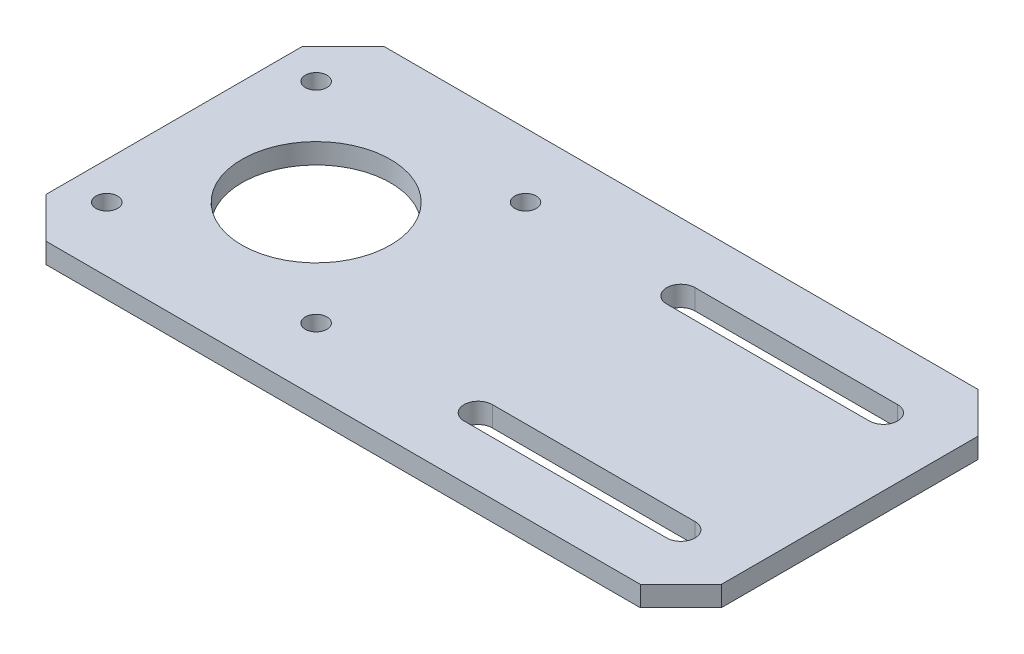
from build123d import *

# Parameters (mm, degrees)
SKETCH_1_W      = 100
SKETCH_1_H      = 50
SKETCH_1_R      = 11
SKETCH_1_R_2    = 1.6
EXTRUDE_1_DEPTH = 3
CHAMFER_1_SIZE  = 6


with BuildPart() as part:
    # 草图1 → 凸台-拉伸1 (new body)
    with BuildSketch(Plane(origin=(0, 0, 0), x_dir=(1, 0, 0), z_dir=(0, 1, 0))):
        with Locations((50, 25)):
            Rectangle(SKETCH_1_W, SKETCH_1_H)
        with Locations((21, 25)):
            Circle(SKETCH_1_R, mode=Mode.SUBTRACT)
        with Locations((5.5, 40.5)):
            Circle(SKETCH_1_R_2, mode=Mode.SUBTRACT)
        with Locations((36.5, 40.5)):
            Circle(SKETCH_1_R_2, mode=Mode.SUBTRACT)
        with Locations((36.5, 9.5)):
            Circle(SKETCH_1_R_2, mode=Mode.SUBTRACT)
        with Locations((5.5, 9.5)):
            Circle(SKETCH_1_R_2, mode=Mode.SUBTRACT)
        with BuildLine():
            Line((60, 42.1), (90, 42.1))
            ThreePointArc((90, 42.1), (92.1, 40), (90, 37.9))
            Line((90, 37.9), (60, 37.9))
            ThreePointArc((60, 37.9), (57.9, 40), (60, 42.1))
        make_face(mode=Mode.SUBTRACT)
        with BuildLine():
            Line((60, 7.9), (90, 7.9))
            ThreePointArc((90, 7.9), (92.1, 10), (90, 12.1))
            Line((90, 12.1), (60, 12.1))
            ThreePointArc((60, 12.1), (57.9, 10), (60, 7.9))
        make_face(mode=Mode.SUBTRACT)
    extrude(amount=EXTRUDE_1_DEPTH)

    # 倒角1
    chamfer_1_edges = [part.edges().sort_by_distance(p)[0] for p in [
        (0, 1.5, -50),
        (100, 1.5, -50),
        (100, 1.5, 0),
        (0, 1.5, 0),
    ]]
    chamfer(chamfer_1_edges, length=CHAMFER_1_SIZE)


solid = part.part
